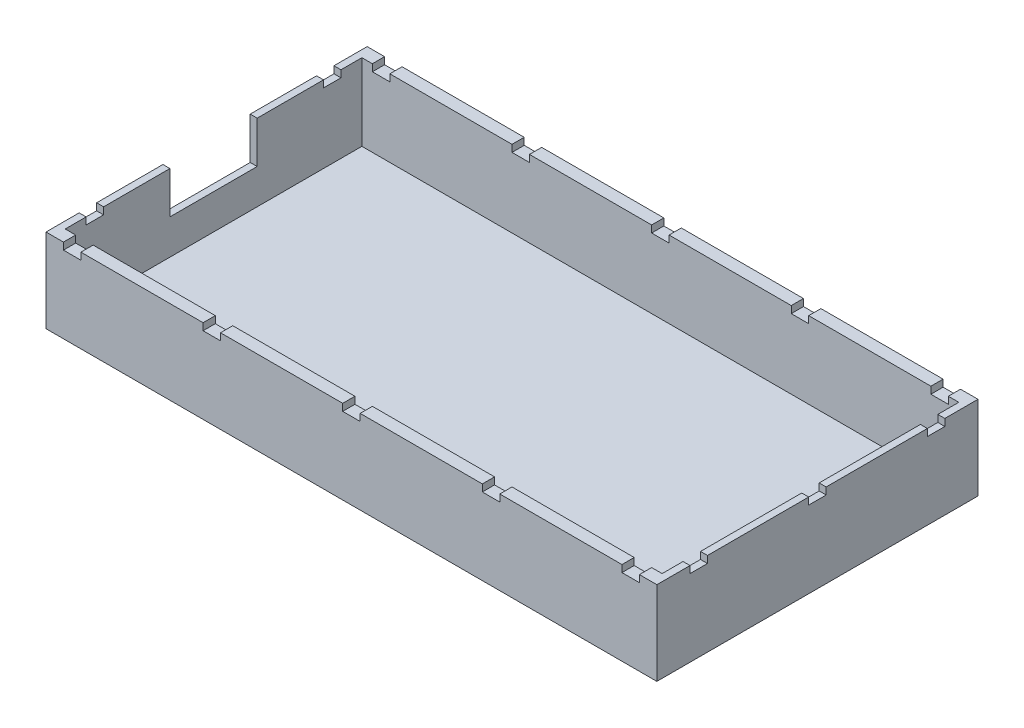
from build123d import *

# Parameters (mm, degrees)
SKETCH1_W           = 175
SKETCH1_H           = 92
BOSS_EXTRUDE1_DEPTH = 24
SKETCH2_W           = 171
SKETCH2_H           = 85
CUT_EXTRUDE1_DEPTH  = 22
SKETCH3_W           = 25
SKETCH3_H           = 12
CUT_EXTRUDE2_DEPTH  = 2
SKETCH4_W           = 5
SKETCH4_H           = 3.5
CUT_EXTRUDE4_DEPTH  = 2
SKETCH5_W           = 5
SKETCH5_H           = 3.5
CUT_EXTRUDE7_DEPTH  = 2
SKETCH7_W           = 2
SKETCH7_H           = 5
CUT_EXTRUDE8_DEPTH  = 2
SKETCH10_W          = 2
SKETCH10_H          = 5
CUT_EXTRUDE9_DEPTH  = 2
SKETCH11_W          = 2
SKETCH11_H          = 5
CUT_EXTRUDE10_DEPTH = 2


with BuildPart() as part:
    # Sketch1 → Boss-Extrude1 (new body)
    with BuildSketch(Plane(origin=(0, 0, 0), x_dir=(1, 0, 0), z_dir=(0, 1, 0))):
        Rectangle(SKETCH1_W, SKETCH1_H)
    extrude(amount=BOSS_EXTRUDE1_DEPTH)

    # Sketch2 → Cut-Extrude1 (cut)
    with BuildSketch(Plane(origin=(0, 24, 0), x_dir=(1, 0, 0), z_dir=(0, 1, 0))):
        Rectangle(SKETCH2_W, SKETCH2_H)
    extrude(amount=-CUT_EXTRUDE1_DEPTH, mode=Mode.SUBTRACT)

    # Sketch3 → Cut-Extrude2 (cut)
    with BuildSketch(Plane.ZY.offset(87.5)):
        with Locations((0, 18)):
            Rectangle(SKETCH3_W, SKETCH3_H)
    extrude(amount=-CUT_EXTRUDE2_DEPTH, mode=Mode.SUBTRACT)

    # Sketch4 → Cut-Extrude4 (cut)
    with BuildSketch(Plane(origin=(0, 24, 0), x_dir=(1, 0, 0), z_dir=(0, 1, 0))):
        with Locations((-80, 44.25)):
            Rectangle(SKETCH4_W, SKETCH4_H)
        with Locations((-40, 44.25)):
            Rectangle(SKETCH4_W, SKETCH4_H)
        with Locations((0, 44.25)):
            Rectangle(SKETCH4_W, SKETCH4_H)
        with Locations((40, 44.25)):
            Rectangle(SKETCH4_W, SKETCH4_H)
        with Locations((80, 44.25)):
            Rectangle(SKETCH4_W, SKETCH4_H)
    extrude(amount=-CUT_EXTRUDE4_DEPTH, mode=Mode.SUBTRACT)

    # Sketch5 → Cut-Extrude7 (cut)
    with BuildSketch(Plane(origin=(0, 24, 0), x_dir=(1, 0, 0), z_dir=(0, 1, 0))):
        with Locations((-80, -44.25)):
            Rectangle(SKETCH5_W, SKETCH5_H)
        with Locations((-40, -44.25)):
            Rectangle(SKETCH5_W, SKETCH5_H)
        with Locations((0, -44.25)):
            Rectangle(SKETCH5_W, SKETCH5_H)
        with Locations((40, -44.25)):
            Rectangle(SKETCH5_W, SKETCH5_H)
        with Locations((80, -44.25)):
            Rectangle(SKETCH5_W, SKETCH5_H)
    extrude(amount=-CUT_EXTRUDE7_DEPTH, mode=Mode.SUBTRACT)

    # Sketch7 → Cut-Extrude8 (cut)
    with BuildSketch(Plane(origin=(0, 24, 0), x_dir=(1, 0, 0), z_dir=(0, 1, 0))):
        with Locations((86.5, 0)):
            Rectangle(SKETCH7_W, SKETCH7_H)
        with Locations((86.5, -34)):
            Rectangle(SKETCH7_W, SKETCH7_H)
        with Locations((86.5, 34)):
            Rectangle(SKETCH7_W, SKETCH7_H)
    extrude(amount=-CUT_EXTRUDE8_DEPTH, mode=Mode.SUBTRACT)

    # Sketch10 → Cut-Extrude9 (cut)
    with BuildSketch(Plane(origin=(0, 24, 0), x_dir=(1, 0, 0), z_dir=(0, 1, 0))):
        with Locations((-86.5, 34)):
            Rectangle(SKETCH10_W, SKETCH10_H)
    extrude(amount=-CUT_EXTRUDE9_DEPTH, mode=Mode.SUBTRACT)

    # Sketch11 → Cut-Extrude10 (cut)
    with BuildSketch(Plane(origin=(0, 24, 0), x_dir=(1, 0, 0), z_dir=(0, 1, 0))):
        with Locations((-86.5, -34)):
            Rectangle(SKETCH11_W, SKETCH11_H)
    extrude(amount=-CUT_EXTRUDE10_DEPTH, mode=Mode.SUBTRACT)


solid = part.part
